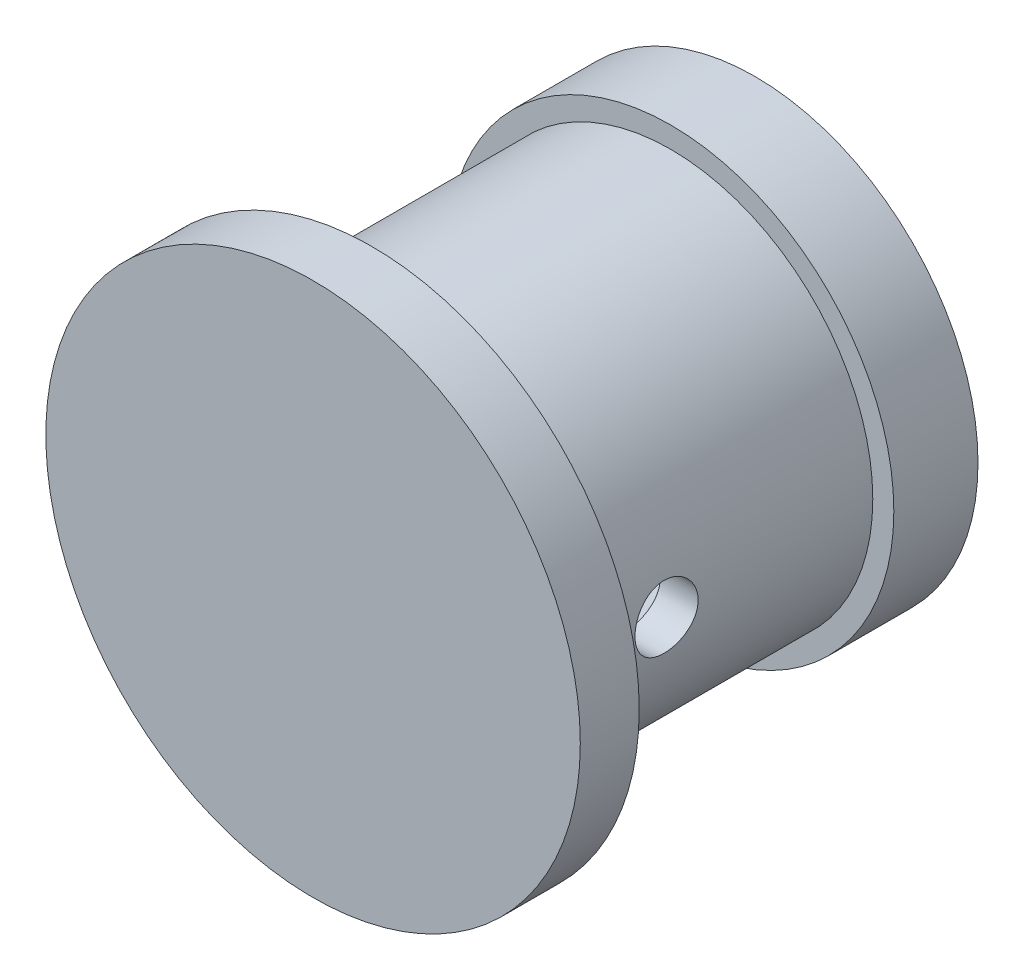
from build123d import *

# Parameters (mm, degrees)
SKETCH1_R           = 5.3
SKETCH1_R_2         = 3.9
EXTRUDE1_DEPTH      = 2
SKETCH2_R           = 4.8
SKETCH2_R_2         = 3.9
EXTRUDE2_DEPTH      = 7.5
SKETCH4_R           = 0.75
EXTRUDE3_DEPTH      = 6.3
EXTRUDE3_DEPTH_BACK = 6.3
SKETCH5_R           = 6.35
EXTRUDE4_DEPTH      = 1
EXTRUDE4_DEPTH_BACK = 0.4


with BuildPart() as part:
    # Sketch1 → Extrude1 (new body)
    with BuildSketch(Plane.XY):
        Circle(SKETCH1_R)
        Circle(SKETCH1_R_2, mode=Mode.SUBTRACT)
    extrude(amount=EXTRUDE1_DEPTH)

    # Sketch2 → Extrude2 (add)
    with BuildSketch(Plane.XY.offset(2)):
        Circle(SKETCH2_R)
        Circle(SKETCH2_R_2, mode=Mode.SUBTRACT)
    extrude(amount=EXTRUDE2_DEPTH)

    # Sketch4 → Extrude3 (cut, two sides)
    with BuildSketch(Plane(origin=(0, 0, 0), x_dir=(0, 0, -1), z_dir=(1, 0, 0))) as extrude3_sk:
        with Locations((-6.9, 0)):
            Circle(SKETCH4_R)
    extrude(amount=EXTRUDE3_DEPTH, mode=Mode.SUBTRACT)
    extrude(extrude3_sk.sketch, amount=-EXTRUDE3_DEPTH_BACK, mode=Mode.SUBTRACT)

    # Sketch5 → Extrude4 (add, two sides)
    with BuildSketch(Plane.XY.offset(9.5)) as extrude4_sk:
        Circle(SKETCH5_R)
    extrude(amount=EXTRUDE4_DEPTH)
    extrude(extrude4_sk.sketch, amount=-EXTRUDE4_DEPTH_BACK)


solid = part.part
